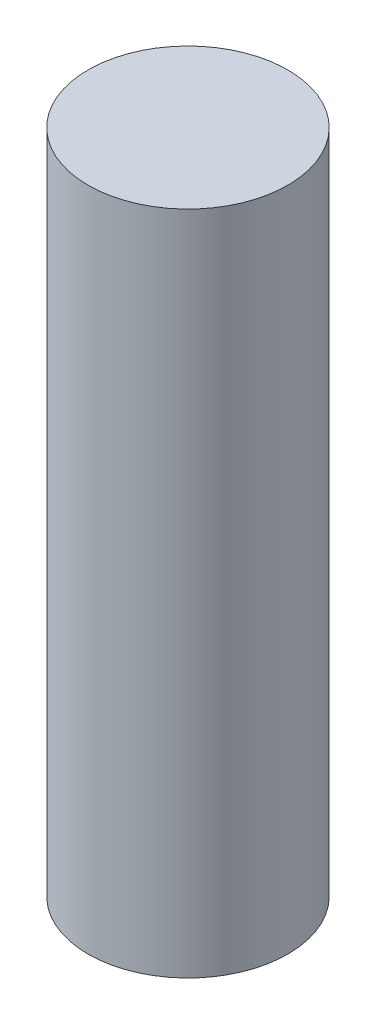
from build123d import *

# Parameters (mm, degrees)
SKETCH1_R           = 3.048
BOSS_EXTRUDE1_DEPTH = 20.32


with BuildPart() as part:
    # Sketch1 → Boss-Extrude1 (new body)
    with BuildSketch(Plane(origin=(0, 0, 0), x_dir=(1, 0, 0), z_dir=(0, 1, 0))):
        Circle(SKETCH1_R)
    extrude(amount=BOSS_EXTRUDE1_DEPTH)


solid = part.part
